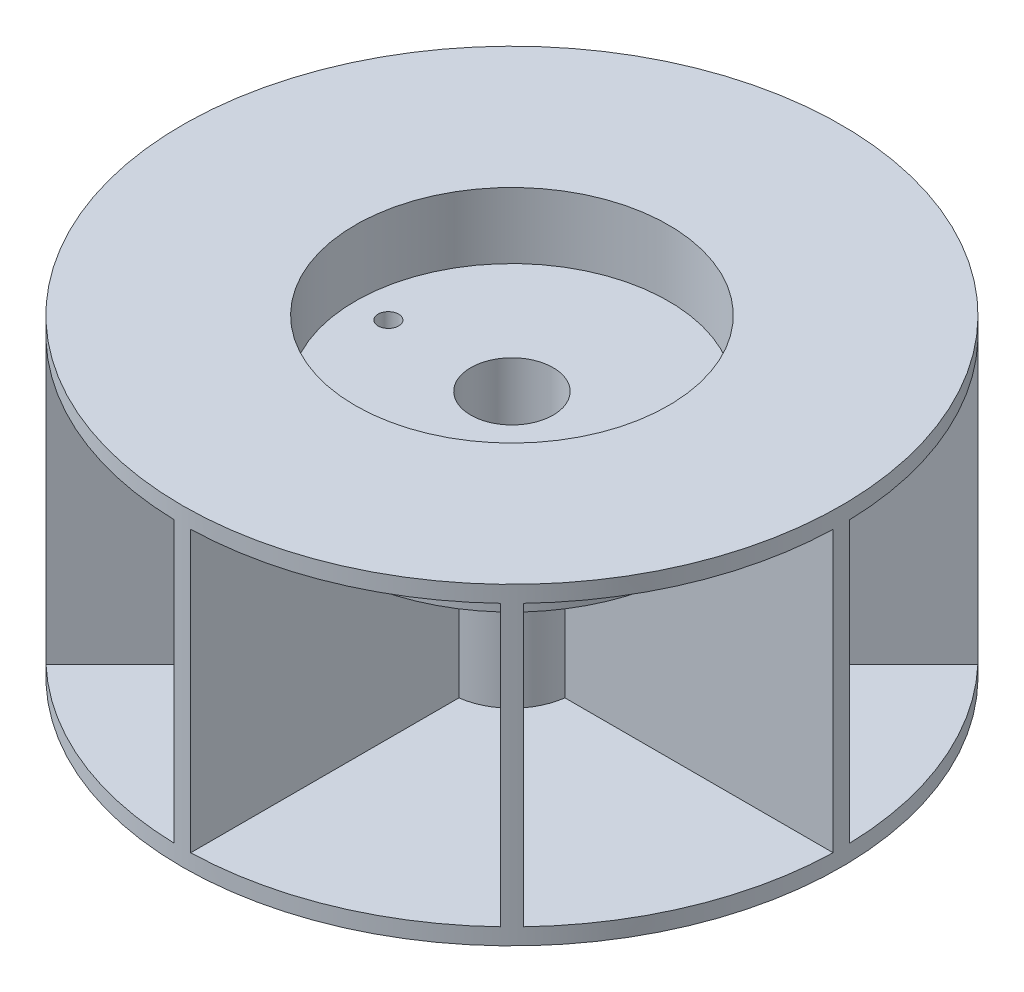
from build123d import *

# Parameters (mm, degrees)
SKETCH1_R                          = 25.4
SKETCH1_R_2                        = 3.175
BOSS_EXTRUDE1_DEPTH                = 1.27
SKETCH2_R                          = 3.175
BOSS_EXTRUDE4_DEPTH                = 12.7
SKETCH5_R                          = 12.065
SKETCH5_R_2                        = 3.175
BOSS_EXTRUDE6_DEPTH                = 2.54
SKETCH9_R                          = 12.065
SKETCH9_R_2                        = 3.175
BOSS_EXTRUDE11_DEPTH               = 2.54
SKETCH5_4_R                        = 12.065
BOSS_EXTRUDE7_DEPTH                = 8.89
SKETCH6_R                          = 25.4
SKETCH6_R_2                        = 12.065
BOSS_EXTRUDE8_DEPTH                = 1.27
F_1_16_0_0625_DIAMETER_HOLE1_D     = 1.5875
F_1_16_0_0625_DIAMETER_HOLE1_DEPTH = 5.08
F_1_16_0_0625_DIAMETER_HOLE1_TIP   = 0.476933116


with BuildPart() as part:
    # Sketch1 → Boss-Extrude1 (new body)
    with BuildSketch(Plane(origin=(0, 0, 0), x_dir=(1, 0, 0), z_dir=(0, 1, 0))):
        Circle(SKETCH1_R)
        Circle(SKETCH1_R_2, mode=Mode.SUBTRACT)
    extrude(amount=BOSS_EXTRUDE1_DEPTH)

    # Sketch2 → Boss-Extrude4 (add)
    with BuildSketch(Plane(origin=(0, 1.27, 0), x_dir=(1, 0, 0), z_dir=(0, 1, 0))):
        with BuildLine():
            ThreePointArc((0.635, 25.392061259), (0, 25.4), (-0.635, 25.392061259))
            Line((-0.635, 25.392061259), (-0.635, 4.719976827))
            ThreePointArc((-0.635, 4.719976827), (-1.822529847, 4.399976274), (-2.888514816, 3.786540428))
            Line((-2.888514816, 3.786540428), (-17.505885899, 18.403911511))
            ThreePointArc((-17.505885899, 18.403911511), (-17.960512242, 17.960512242), (-18.403911511, 17.505885899))
            Line((-18.403911511, 17.505885899), (-3.786540428, 2.888514816))
            ThreePointArc((-3.786540428, 2.888514816), (-4.399976274, 1.822529847), (-4.719976827, 0.635))
            Line((-4.719976827, 0.635), (-25.392061259, 0.635))
            ThreePointArc((-25.392061259, 0.635), (-25.4, 0), (-25.392061259, -0.635))
            Line((-25.392061259, -0.635), (-4.719976827, -0.635))
            ThreePointArc((-4.719976827, -0.635), (-4.399976274, -1.822529847), (-3.786540428, -2.888514816))
            Line((-3.786540428, -2.888514816), (-18.403911511, -17.505885899))
            ThreePointArc((-18.403911511, -17.505885899), (-17.960512242, -17.960512242), (-17.505885899, -18.403911511))
            Line((-17.505885899, -18.403911511), (-2.888514816, -3.786540428))
            ThreePointArc((-2.888514816, -3.786540428), (-1.822529847, -4.399976274), (-0.635, -4.719976827))
            Line((-0.635, -4.719976827), (-0.635, -25.392061259))
            ThreePointArc((-0.635, -25.392061259), (0, -25.4), (0.635, -25.392061259))
            Line((0.635, -25.392061259), (0.635, -4.719976827))
            ThreePointArc((0.635, -4.719976827), (1.822529847, -4.399976274), (2.888514816, -3.786540428))
            Line((2.888514816, -3.786540428), (17.505885899, -18.403911511))
            ThreePointArc((17.505885899, -18.403911511), (17.960512242, -17.960512242), (18.403911511, -17.505885899))
            Line((18.403911511, -17.505885899), (3.786540428, -2.888514816))
            ThreePointArc((3.786540428, -2.888514816), (4.399976274, -1.822529847), (4.719976827, -0.635))
            Line((4.719976827, -0.635), (25.392061259, -0.635))
            ThreePointArc((25.392061259, -0.635), (25.4, 0), (25.392061259, 0.635))
            Line((25.392061259, 0.635), (4.719976827, 0.635))
            ThreePointArc((4.719976827, 0.635), (4.399976274, 1.822529847), (3.786540428, 2.888514816))
            Line((3.786540428, 2.888514816), (18.403911511, 17.505885899))
            ThreePointArc((18.403911511, 17.505885899), (17.960512242, 17.960512242), (17.505885899, 18.403911511))
            Line((17.505885899, 18.403911511), (2.888514816, 3.786540428))
            ThreePointArc((2.888514816, 3.786540428), (1.822529847, 4.399976274), (0.635, 4.719976827))
            Line((0.635, 4.719976827), (0.635, 25.392061259))
        make_face()
        Circle(SKETCH2_R, mode=Mode.SUBTRACT)
    extrude(amount=BOSS_EXTRUDE4_DEPTH)

    # Sketch5 → Boss-Extrude6 (add)
    with BuildSketch(Plane(origin=(0, 13.97, 0), x_dir=(1, 0, 0), z_dir=(0, 1, 0))):
        Circle(SKETCH5_R)
        Circle(SKETCH5_R_2, mode=Mode.SUBTRACT)
    extrude(amount=BOSS_EXTRUDE6_DEPTH)

    # Sketch9 → Boss-Extrude11 (add)
    with BuildSketch(Plane(origin=(0, 16.51, 0), x_dir=(1, 0, 0), z_dir=(0, 1, 0))):
        Circle(SKETCH9_R)
        Circle(SKETCH9_R_2, mode=Mode.SUBTRACT)
    extrude(amount=BOSS_EXTRUDE11_DEPTH)

    # Sketch5_4 → Boss-Extrude7 (add)
    with BuildSketch(Plane(origin=(0, 13.97, 0), x_dir=(1, 0, 0), z_dir=(0, 1, 0))):
        with BuildLine():
            ThreePointArc((0.635, -13.637724563), (5.22458556, -12.613265318), (9.194314712, -10.092340324))
            Line((9.194314712, -10.092340324), (17.505885899, -18.403911511))
            ThreePointArc((17.505885899, -18.403911511), (17.960512242, -17.960512242), (18.403911511, -17.505885899))
            Line((18.403911511, -17.505885899), (10.092340324, -9.194314712))
            ThreePointArc((10.092340324, -9.194314712), (12.613265318, -5.22458556), (13.637724563, -0.635))
            Line((13.637724563, -0.635), (25.392061259, -0.635))
            ThreePointArc((25.392061259, -0.635), (25.4, 0), (25.392061259, 0.635))
            Line((25.392061259, 0.635), (13.637724563, 0.635))
            ThreePointArc((13.637724563, 0.635), (12.613265318, 5.22458556), (10.092340324, 9.194314712))
            Line((10.092340324, 9.194314712), (18.403911511, 17.505885899))
            ThreePointArc((18.403911511, 17.505885899), (17.960512242, 17.960512242), (17.505885899, 18.403911511))
            Line((17.505885899, 18.403911511), (9.194314712, 10.092340324))
            ThreePointArc((9.194314712, 10.092340324), (5.22458556, 12.613265318), (0.635, 13.637724563))
            Line((0.635, 13.637724563), (0.635, 25.392061259))
            ThreePointArc((0.635, 25.392061259), (0, 25.4), (-0.635, 25.392061259))
            Line((-0.635, 25.392061259), (-0.635, 13.637724563))
            ThreePointArc((-0.635, 13.637724563), (-5.22458556, 12.613265318), (-9.194314712, 10.092340324))
            Line((-9.194314712, 10.092340324), (-17.505885899, 18.403911511))
            ThreePointArc((-17.505885899, 18.403911511), (-17.960512242, 17.960512242), (-18.403911511, 17.505885899))
            Line((-18.403911511, 17.505885899), (-10.092340324, 9.194314712))
            ThreePointArc((-10.092340324, 9.194314712), (-12.613265318, 5.22458556), (-13.637724563, 0.635))
            Line((-13.637724563, 0.635), (-25.392061259, 0.635))
            ThreePointArc((-25.392061259, 0.635), (-25.4, 0), (-25.392061259, -0.635))
            Line((-25.392061259, -0.635), (-13.637724563, -0.635))
            ThreePointArc((-13.637724563, -0.635), (-12.613265318, -5.22458556), (-10.092340324, -9.194314712))
            Line((-10.092340324, -9.194314712), (-18.403911511, -17.505885899))
            ThreePointArc((-18.403911511, -17.505885899), (-17.960512242, -17.960512242), (-17.505885899, -18.403911511))
            Line((-17.505885899, -18.403911511), (-9.194314712, -10.092340324))
            ThreePointArc((-9.194314712, -10.092340324), (-5.22458556, -12.613265318), (-0.635, -13.637724563))
            Line((-0.635, -13.637724563), (-0.635, -25.392061259))
            ThreePointArc((-0.635, -25.392061259), (0, -25.4), (0.635, -25.392061259))
            Line((0.635, -25.392061259), (0.635, -13.637724563))
        make_face()
        Circle(SKETCH5_4_R, mode=Mode.SUBTRACT)
    extrude(amount=BOSS_EXTRUDE7_DEPTH)

    # Sketch6 → Boss-Extrude8 (add)
    with BuildSketch(Plane(origin=(0, 22.86, 0), x_dir=(1, 0, 0), z_dir=(0, 1, 0))):
        Circle(SKETCH6_R)
        Circle(SKETCH6_R_2, mode=Mode.SUBTRACT)
    extrude(amount=BOSS_EXTRUDE8_DEPTH)

    # 1_16 _0.0625_ Diameter Hole1
    with Locations(Plane(origin=(0, 19.05, 0), x_dir=(1, 0, 0), z_dir=(0, 1, 0))):
        with Locations((-9.525, 0), (9.525, 0)):
            Hole(F_1_16_0_0625_DIAMETER_HOLE1_D / 2, depth=F_1_16_0_0625_DIAMETER_HOLE1_DEPTH)
            with Locations((0, 0, -(F_1_16_0_0625_DIAMETER_HOLE1_DEPTH + F_1_16_0_0625_DIAMETER_HOLE1_TIP / 2))):  # 118° drill point
                Cone(0, F_1_16_0_0625_DIAMETER_HOLE1_D / 2, F_1_16_0_0625_DIAMETER_HOLE1_TIP, mode=Mode.SUBTRACT)


solid = part.part
